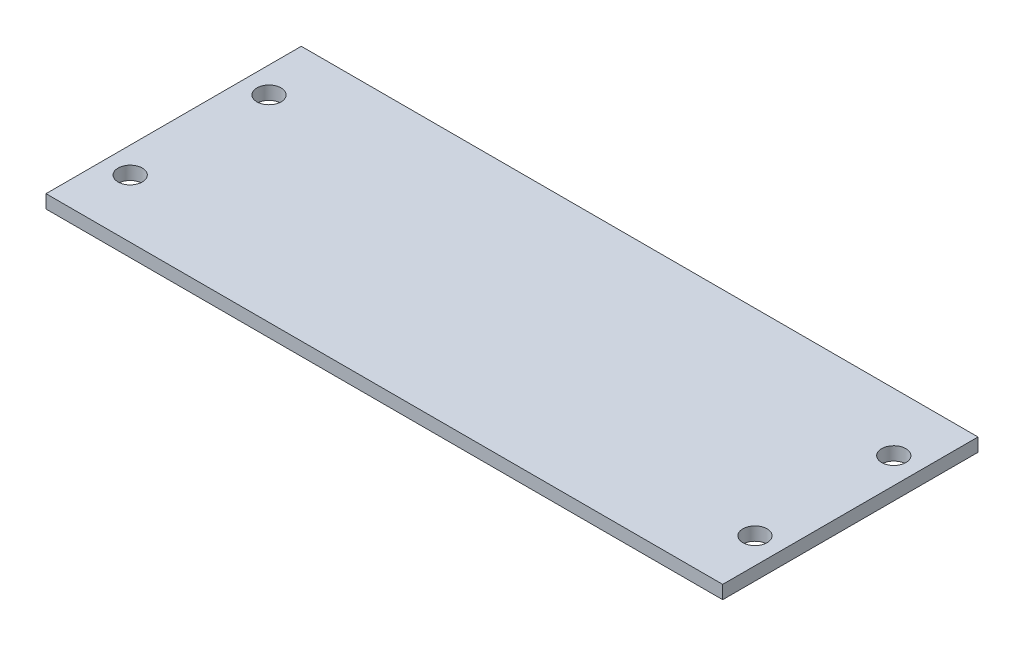
from build123d import *

# Parameters (mm, degrees)
SKETCH1_W           = 55.88
SKETCH1_H           = 21.082
SKETCH1_R           = 1
BOSS_EXTRUDE1_DEPTH = 1.1


with BuildPart() as part:
    # Sketch1 → Boss-Extrude1 (new body)
    with BuildSketch(Plane(origin=(0, 0, 0), x_dir=(1, 0, 0), z_dir=(0, 1, 0))):
        with Locations((27.94, 10.541)):
            Rectangle(SKETCH1_W, SKETCH1_H)
        with Locations((2.143, 16.272)):
            Circle(SKETCH1_R, mode=Mode.SUBTRACT)
        with Locations((2.143, 4.81)):
            Circle(SKETCH1_R, mode=Mode.SUBTRACT)
        with Locations((53.737, 16.272)):
            Circle(SKETCH1_R, mode=Mode.SUBTRACT)
        with Locations((53.737, 4.81)):
            Circle(SKETCH1_R, mode=Mode.SUBTRACT)
    extrude(amount=BOSS_EXTRUDE1_DEPTH)


solid = part.part
